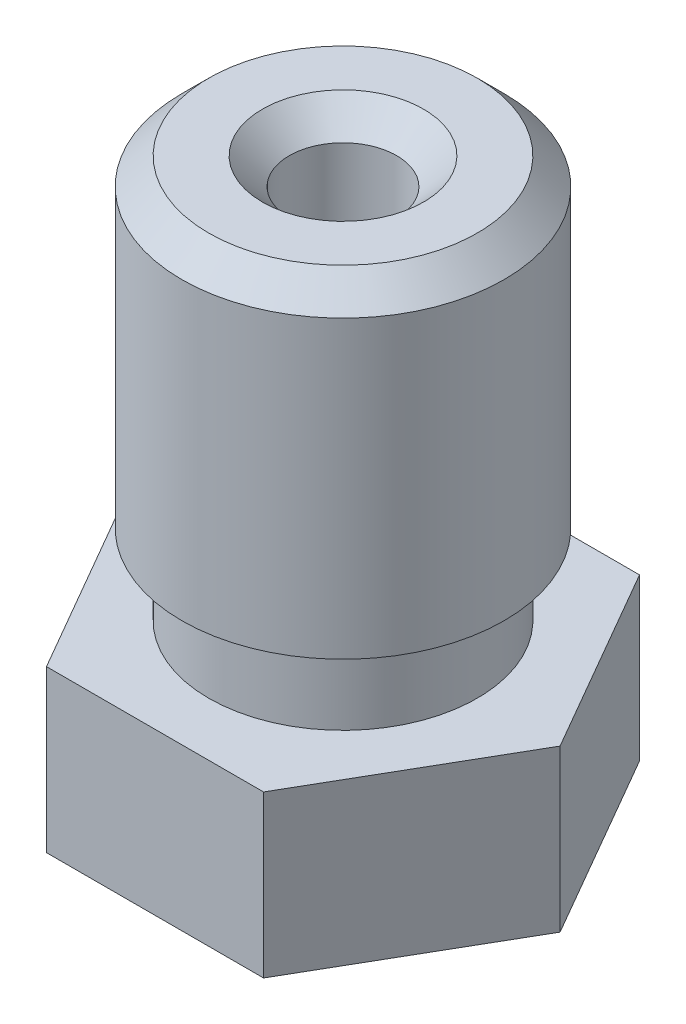
from build123d import *

# Parameters (mm, degrees)
BOSS_EXTRUDE1_DEPTH = 3
CHAMFER1_SIZE       = 0.5


with BuildPart() as part:
    # Sketch1 → Boss-Extrude1 (new body)
    with BuildSketch(Plane.XZ):
        Polygon((-2.020725942, 3.5), (-4.041451884, 0), (-2.020725942, -3.5), (2.020725942, -3.5), (4.041451884, 0), (2.020725942, 3.5), align=None)
    extrude(amount=-BOSS_EXTRUDE1_DEPTH)

    # Sketch2 → Revolve1 (revolve)
    with BuildSketch(Plane(origin=(0, 0, 0), x_dir=(-1, 0, 0), z_dir=(0, 0, -1))):
        Polygon((-2.5, 3), (0, 3), (0, 10.5), (-3, 10.5), (-3, 4.5), (-2.5, 4.5), align=None)
    revolve(axis=Axis((0, 3, 0), (0, 1, 0)))

    # Sketch3 → Revolve2 (revolve)
    with BuildSketch(Plane.XY):
        Polygon((2.5, 0), (0, 0), (0, -2), (0.5, -2), align=None)
    revolve(axis=Axis((0, 0, 0), (0, -1, 0)))

    # Sketch4 → Cut-Revolve1 (revolve, cut)
    with BuildSketch(Plane(origin=(0, 0, 0), x_dir=(-1, 0, 0), z_dir=(0, 0, -1))):
        Polygon((-0.05, -2), (0, -2), (0, 10.5), (-1, 10.5), (-1, 0), (-0.75, -0.227272727), (-0.75, -0.7), (-0.05, -1.2), align=None)
    revolve(axis=Axis((0, -2, 0), (0, 1, 0)), mode=Mode.SUBTRACT)

    # Chamfer1
    chamfer1_edges = [part.edges().sort_by_distance(p)[0] for p in [
        (-3, 10.5, 0),
        (-1, 10.5, 0),
    ]]
    chamfer(chamfer1_edges, length=CHAMFER1_SIZE)


solid = part.part
